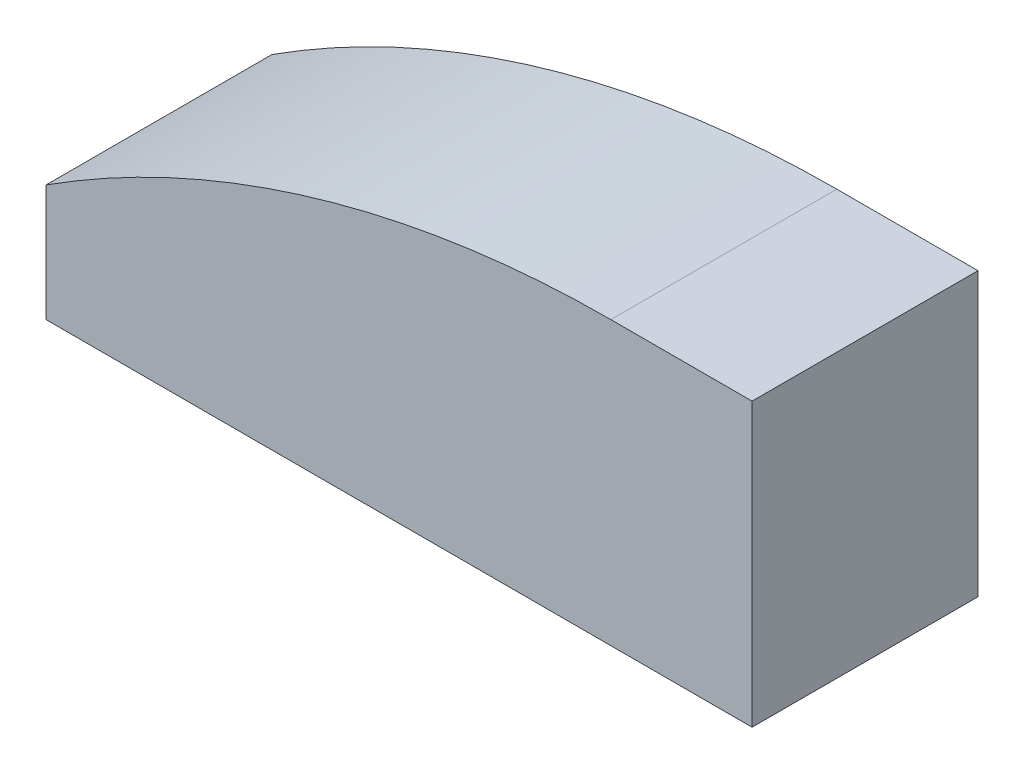
from build123d import *

# Parameters (mm, degrees)
BOSS_EXTRUDE1_DEPTH = 20


with BuildPart() as part:
    # Sketch1 → Boss-Extrude1 (new body, symmetric)
    with BuildSketch(Plane.XY):
        with BuildLine():
            Line((0, -50), (-125, -50))
            Line((-125, -50), (-125, -29.356175837))
            ThreePointArc((-125, -29.356175837), (-77.109944012, -7.490693948), (-25, 0))
            Line((-25, 0), (0, 0))
            Line((0, 0), (0, -50))
        make_face()
    extrude(amount=BOSS_EXTRUDE1_DEPTH, both=True)


solid = part.part
